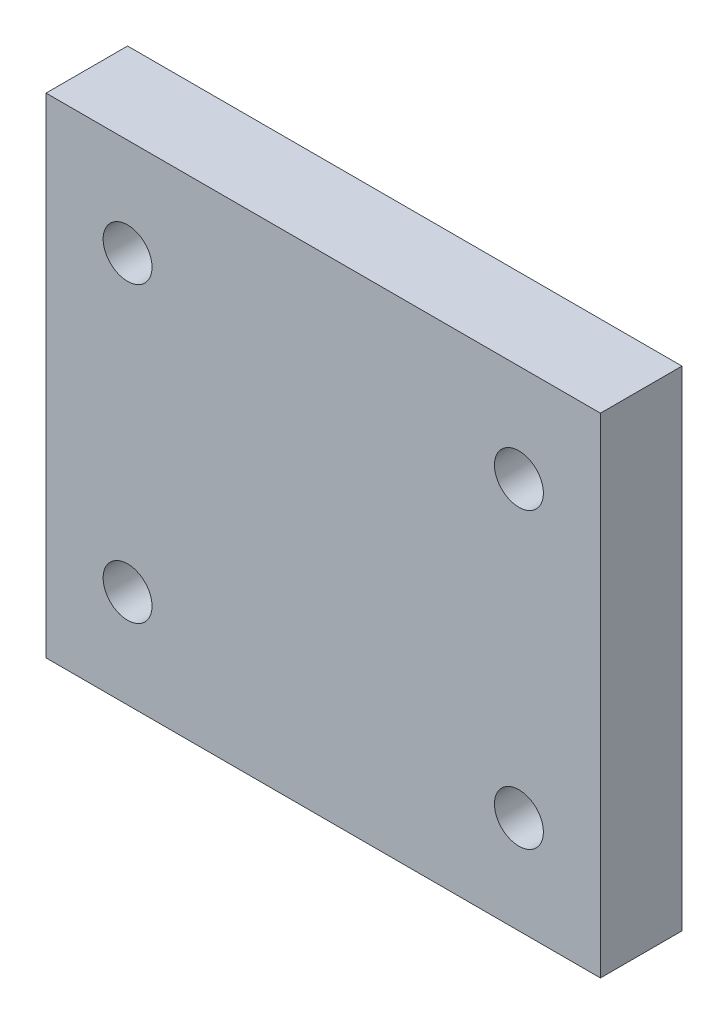
from build123d import *

# Parameters (mm, degrees)
SKETCH1_W           = 34
SKETCH1_H           = 30
BOSS_EXTRUDE1_DEPTH = 5
SKETCH2_R           = 1.5
CUT_EXTRUDE1_DEPTH  = 6


with BuildPart() as part:
    # Sketch1 → Boss-Extrude1 (new body)
    with BuildSketch(Plane.XY):
        Rectangle(SKETCH1_W, SKETCH1_H)
    extrude(amount=BOSS_EXTRUDE1_DEPTH)

    # Sketch2 → Cut-Extrude1 (cut, through all)
    with BuildSketch(Plane(origin=(0, 0, 0), x_dir=(-1, 0, 0), z_dir=(0, 0, -1))):
        with Locations((12, 9)):
            Circle(SKETCH2_R)
        with Locations((-12, 9)):
            Circle(SKETCH2_R)
        with Locations((12, -9)):
            Circle(SKETCH2_R)
        with Locations((-12, -9)):
            Circle(SKETCH2_R)
    extrude(amount=-CUT_EXTRUDE1_DEPTH, mode=Mode.SUBTRACT)


solid = part.part
